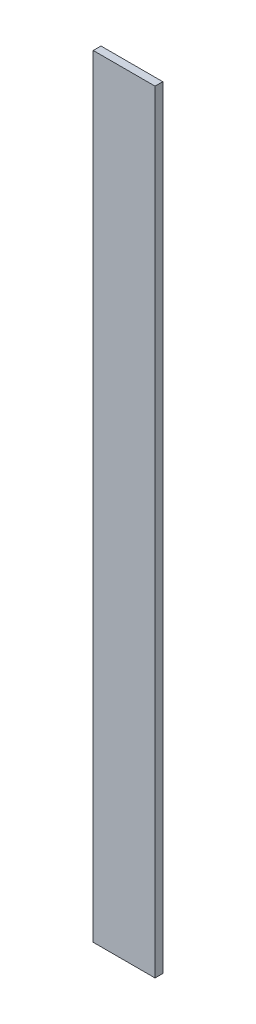
from build123d import *

# Parameters (mm, degrees)
SKETCH1_W           = 50.8
SKETCH1_H           = 6.35
BOSS_EXTRUDE1_DEPTH = 317.5


with BuildPart() as part:
    # Sketch1 → Boss-Extrude1 (new body, symmetric)
    with BuildSketch(Plane(origin=(0, 0, 0), x_dir=(1, 0, 0), z_dir=(0, 1, 0))):
        with Locations((25.4, -3.175)):
            Rectangle(SKETCH1_W, SKETCH1_H)
    extrude(amount=BOSS_EXTRUDE1_DEPTH, both=True)


solid = part.part
